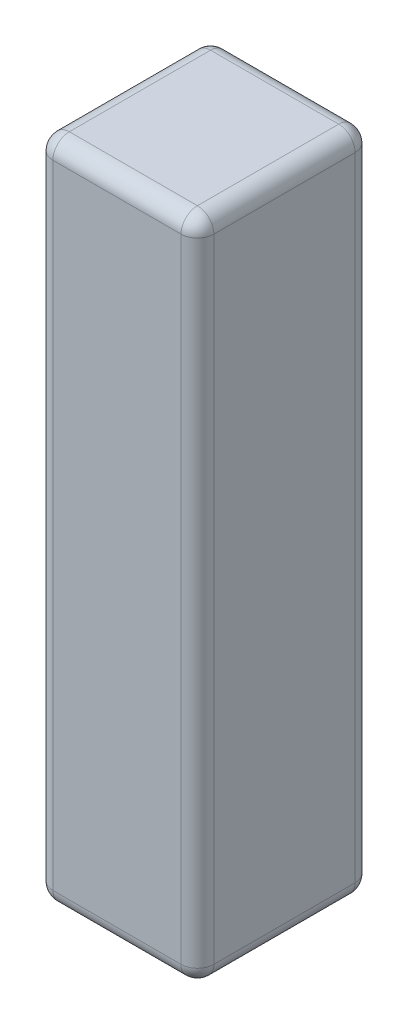
from build123d import *

# Parameters (mm, degrees)
SKETCH1_W           = 24.892
SKETCH1_H           = 26.924
BOSS_EXTRUDE1_DEPTH = 102.87
FILLET1_R           = 2.54


with BuildPart() as part:
    # Sketch1 → Boss-Extrude1 (new body)
    with BuildSketch(Plane(origin=(0, 0, 0), x_dir=(1, 0, 0), z_dir=(0, 1, 0))):
        Rectangle(SKETCH1_W, SKETCH1_H)
    extrude(amount=BOSS_EXTRUDE1_DEPTH)

    # Fillet1
    fillet1_edges = [part.edges().sort_by_distance(p)[0] for p in [
        (12.446, 102.87, 0),
        (0, 102.87, -13.462),
        (-12.446, 102.87, 0),
        (0, 0, -13.462),
        (12.446, 0, 0),
        (0, 0, 13.462),
        (-12.446, 0, 0),
        (-12.446, 51.435, -13.462),
        (12.446, 51.435, -13.462),
        (12.446, 51.435, 13.462),
        (-12.446, 51.435, 13.462),
        (0, 102.87, 13.462),
    ]]
    fillet(fillet1_edges, radius=FILLET1_R)


solid = part.part
